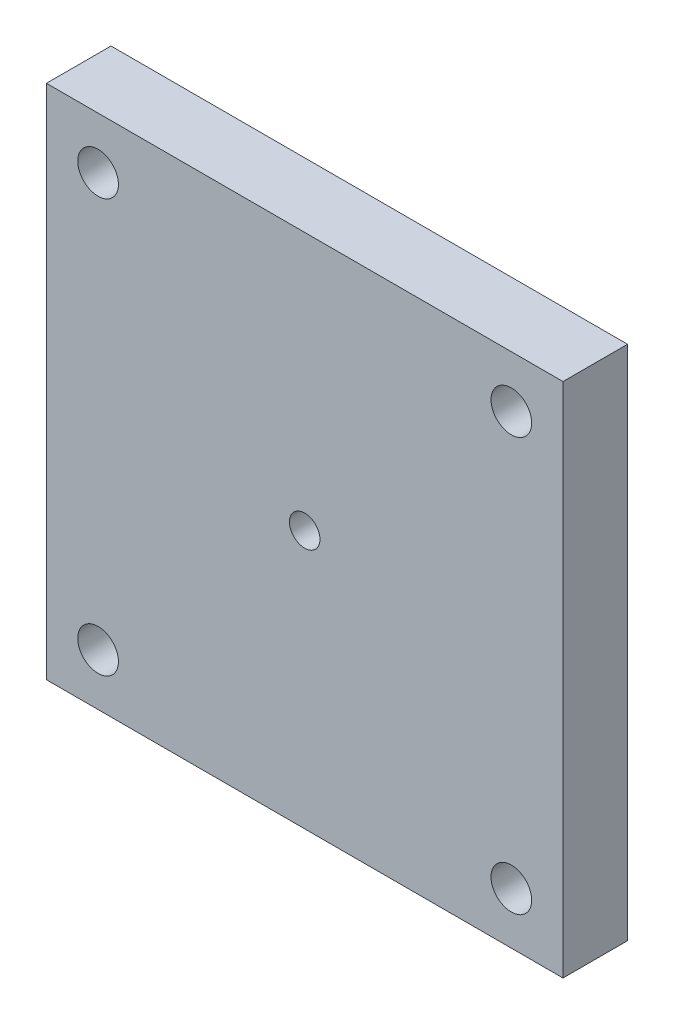
from build123d import *

# Parameters (mm, degrees)
SKETCH2_W           = 50.8
SKETCH2_H           = 50.8
SKETCH2_R           = 2
SKETCH2_R_2         = 1.4986
BOSS_EXTRUDE1_DEPTH = 6.35


with BuildPart() as part:
    # Sketch2 → Boss-Extrude1 (new body)
    with BuildSketch(Plane.XY):
        with Locations((25.4, 25.4)):
            Rectangle(SKETCH2_W, SKETCH2_H)
        with Locations((5.08, 45.72)):
            Circle(SKETCH2_R, mode=Mode.SUBTRACT)
        with Locations((45.72, 45.72)):
            Circle(SKETCH2_R, mode=Mode.SUBTRACT)
        with Locations((45.72, 5.08)):
            Circle(SKETCH2_R, mode=Mode.SUBTRACT)
        with Locations((5.08, 5.08)):
            Circle(SKETCH2_R, mode=Mode.SUBTRACT)
        with Locations((25.4, 25.4)):
            Circle(SKETCH2_R_2, mode=Mode.SUBTRACT)
    extrude(amount=BOSS_EXTRUDE1_DEPTH)


solid = part.part
